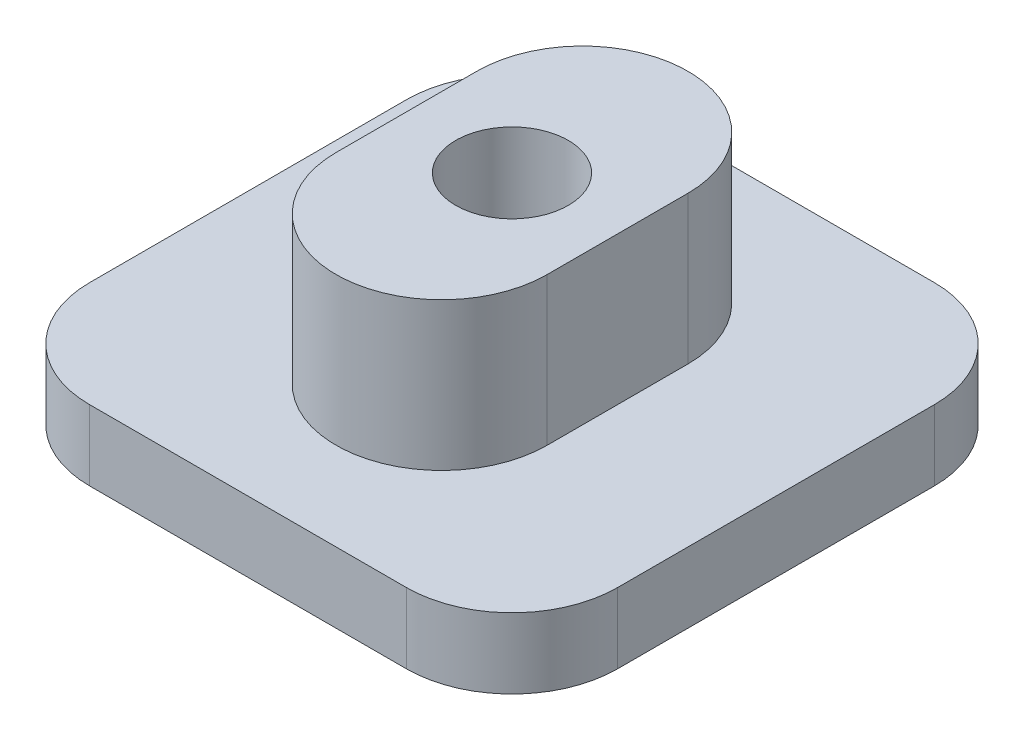
from build123d import *

# Parameters (mm, degrees)
SKETCH1_R               = 1.6
BOSS_EXTRUDE1_DEPTH     = 4.2
SKETCH2_W               = 15
SKETCH2_H               = 15
BOSS_EXTRUDE2_DEPTH     = 2
FILLET1_R               = 3
SKETCH3_R               = 1.6
CUT_EXTRUDE1_DEPTH      = 5.2
CUT_EXTRUDE1_DEPTH_BACK = 3


with BuildPart() as part:
    # Sketch1 → Boss-Extrude1 (new body)
    with BuildSketch(Plane(origin=(0, 0, 0), x_dir=(1, 0, 0), z_dir=(0, 1, 0))):
        with BuildLine():
            Line((-3, -2), (-3, 2))
            ThreePointArc((-3, 2), (0, 5), (3, 2))
            Line((3, 2), (3, -2))
            ThreePointArc((3, -2), (0, -5), (-3, -2))
        make_face()
        Circle(SKETCH1_R, mode=Mode.SUBTRACT)
    extrude(amount=BOSS_EXTRUDE1_DEPTH)

    # Sketch2 → Boss-Extrude2 (add)
    with BuildSketch(Plane.XZ):
        Rectangle(SKETCH2_W, SKETCH2_H)
    extrude(amount=BOSS_EXTRUDE2_DEPTH)

    # Fillet1
    fillet1_edges = [part.edges().sort_by_distance(p)[0] for p in [
        (-7.5, -1, 7.5),
        (-7.5, -1, -7.5),
        (7.5, -1, -7.5),
        (7.5, -1, 7.5),
    ]]
    fillet(fillet1_edges, radius=FILLET1_R)

    # Sketch3 → Cut-Extrude1 (cut, two sides)
    with BuildSketch(Plane(origin=(0, 0, 0), x_dir=(1, 0, 0), z_dir=(0, 1, 0))) as cut_extrude1_sk:
        Circle(SKETCH3_R)
    extrude(amount=CUT_EXTRUDE1_DEPTH, mode=Mode.SUBTRACT)
    extrude(cut_extrude1_sk.sketch, amount=-CUT_EXTRUDE1_DEPTH_BACK, mode=Mode.SUBTRACT)


solid = part.part
